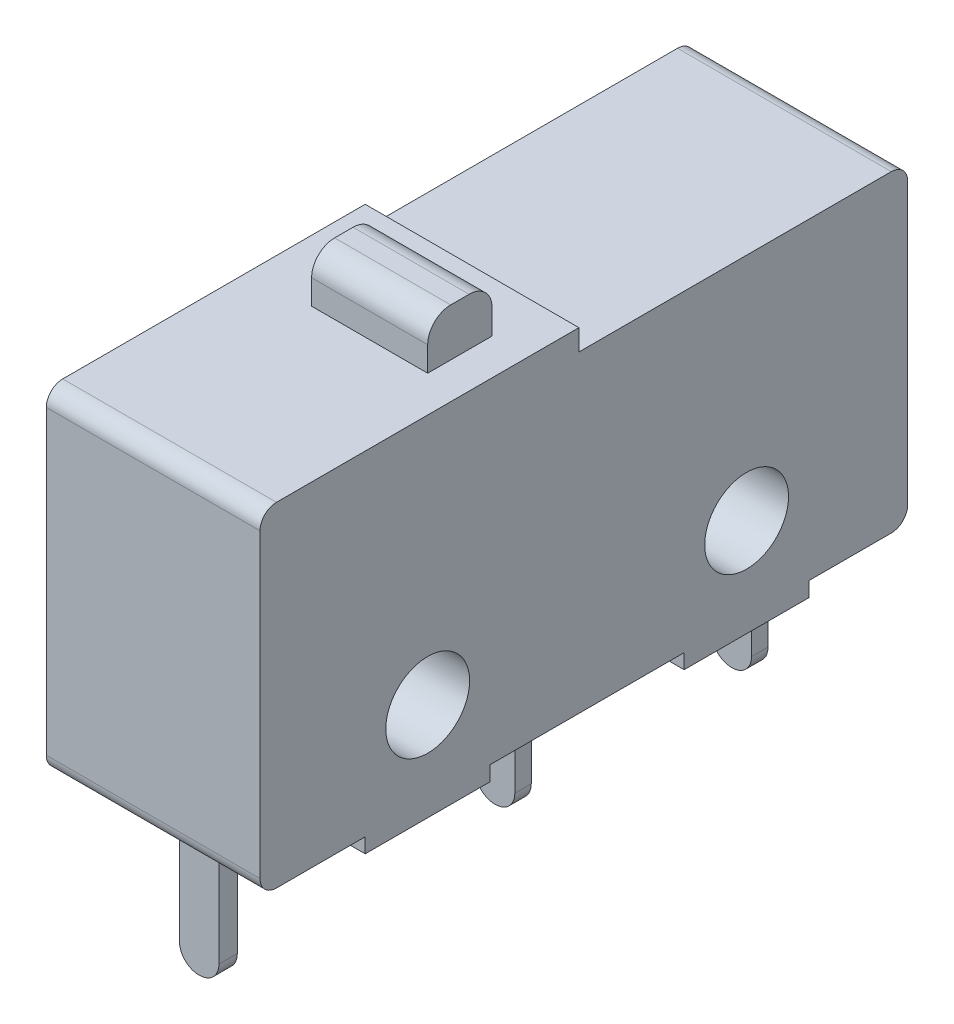
from build123d import *

# Parameters (mm, degrees)
SKETCH1_R           = 1.275
BOSS_EXTRUDE1_DEPTH = 6.5
SKETCH2_W           = 3.53
SKETCH2_H           = 1.96
BOSS_EXTRUDE2_DEPTH = 1.45
FILLET1_R           = 0.7
SKETCH3_W           = 3.2
SKETCH3_H           = 0.56
SKETCH3_H_2         = 0.5
BOSS_EXTRUDE3_DEPTH = 0.9
SKETCH4_W           = 1.2
SKETCH4_H           = 0.56
SKETCH4_H_2         = 0.5
BOSS_EXTRUDE4_DEPTH = 3.47
FILLET2_R           = 0.59


with BuildPart() as part:
    # Sketch1 → Boss-Extrude1 (new body)
    with BuildSketch(Plane(origin=(0, 0, 0), x_dir=(0, 0, -1), z_dir=(1, 0, 0))):
        with BuildLine():
            Line((-37.373122581, 0), (-34.673122581, 0))
            Line((-34.673122581, 0), (-34.673122581, -0.45))
            Line((-34.673122581, -0.45), (-30.873122581, -0.45))
            Line((-30.873122581, -0.45), (-30.873122581, 0))
            Line((-30.873122581, 0), (-24.973122581, 0))
            Line((-24.973122581, 0), (-24.973122581, -0.45))
            Line((-24.973122581, -0.45), (-21.173122581, -0.45))
            Line((-21.173122581, -0.45), (-21.173122581, 0))
            Line((-21.173122581, 0), (-18.673122581, 0))
            ThreePointArc((-18.673122581, 0), (-18.31956919, 0.146446609), (-18.173122581, 0.5))
            Line((-18.173122581, 0.5), (-18.173122581, 9.02))
            ThreePointArc((-18.173122581, 9.02), (-18.31956919, 9.373553391), (-18.673122581, 9.52))
            Line((-18.673122581, 9.52), (-28.173122581, 9.52))
            Line((-28.173122581, 9.52), (-28.173122581, 10.16))
            Line((-28.173122581, 10.16), (-37.373122581, 10.16))
            ThreePointArc((-37.373122581, 10.16), (-37.726675972, 10.013553391), (-37.873122581, 9.66))
            Line((-37.873122581, 9.66), (-37.873122581, 0.5))
            ThreePointArc((-37.873122581, 0.5), (-37.726675972, 0.146446609), (-37.373122581, 0))
        make_face()
        with Locations((-32.773122581, 2.525)):
            Circle(SKETCH1_R, mode=Mode.SUBTRACT)
        with Locations((-23.073122581, 2.525)):
            Circle(SKETCH1_R, mode=Mode.SUBTRACT)
    extrude(amount=BOSS_EXTRUDE1_DEPTH)

    # Sketch2 → Boss-Extrude2 (add)
    with BuildSketch(Plane(origin=(0, 10.16, 0), x_dir=(1, 0, 0), z_dir=(0, 1, 0))):
        with Locations((3.635, -30.693122581)):
            Rectangle(SKETCH2_W, SKETCH2_H)
    extrude(amount=BOSS_EXTRUDE2_DEPTH)

    # Fillet1
    fillet1_edges = [part.edges().sort_by_distance(p)[0] for p in [
        (3.635, 11.61, 31.673122581),
        (3.635, 11.61, 29.713122581),
    ]]
    fillet(fillet1_edges, radius=FILLET1_R)

    # Sketch3 → Boss-Extrude3 (add)
    with BuildSketch(Plane(origin=(0, 0, 0), x_dir=(-1, 0, 0), z_dir=(0, -1, 0))):
        with Locations((-3.25, -36.193122581)):
            Rectangle(SKETCH3_W, SKETCH3_H)
        with Locations((-3.25, -27.223122581)):
            Rectangle(SKETCH3_W, SKETCH3_H_2)
        with Locations((-3.25, -20.023122581)):
            Rectangle(SKETCH3_W, SKETCH3_H_2)
    extrude(amount=BOSS_EXTRUDE3_DEPTH)

    # Sketch4 → Boss-Extrude4 (add)
    with BuildSketch(Plane(origin=(0, -0.9, 0), x_dir=(-1, 0, 0), z_dir=(0, -1, 0))):
        with Locations((-3.25, -36.193122581)):
            Rectangle(SKETCH4_W, SKETCH4_H)
        with Locations((-3.25, -27.223122581)):
            Rectangle(SKETCH4_W, SKETCH4_H_2)
        with Locations((-3.25, -20.023122581)):
            Rectangle(SKETCH4_W, SKETCH4_H_2)
    extrude(amount=BOSS_EXTRUDE4_DEPTH)

    # Fillet2
    fillet2_edges = [part.edges().sort_by_distance(p)[0] for p in [
        (2.65, -4.37, 36.193122581),
        (3.85, -4.37, 36.193122581),
        (2.65, -4.37, 27.223122581),
        (3.85, -4.37, 27.223122581),
        (3.85, -4.37, 20.023122581),
        (2.65, -4.37, 20.023122581),
    ]]
    fillet(fillet2_edges, radius=FILLET2_R)


solid = part.part
